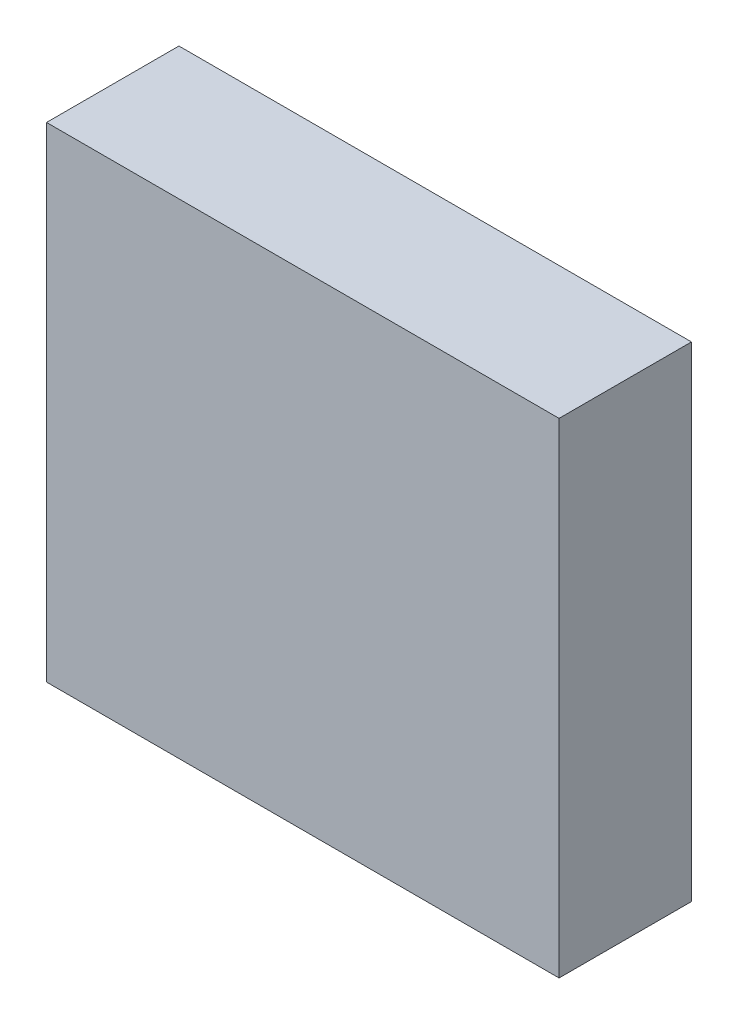
from build123d import *

# Parameters (mm, degrees)
SKICA1_W                = 38.713548651
SKICA1_H                = 36.609551442
P_IDAT_VYSUNUT_M1_DEPTH = 10


with BuildPart() as part:
    # Skica1 → Přidat vysunutím1 (new body)
    with BuildSketch(Plane.XY):
        with Locations((-47.971136373, 8.415988837)):
            Rectangle(SKICA1_W, SKICA1_H)
    extrude(amount=P_IDAT_VYSUNUT_M1_DEPTH)


solid = part.part
